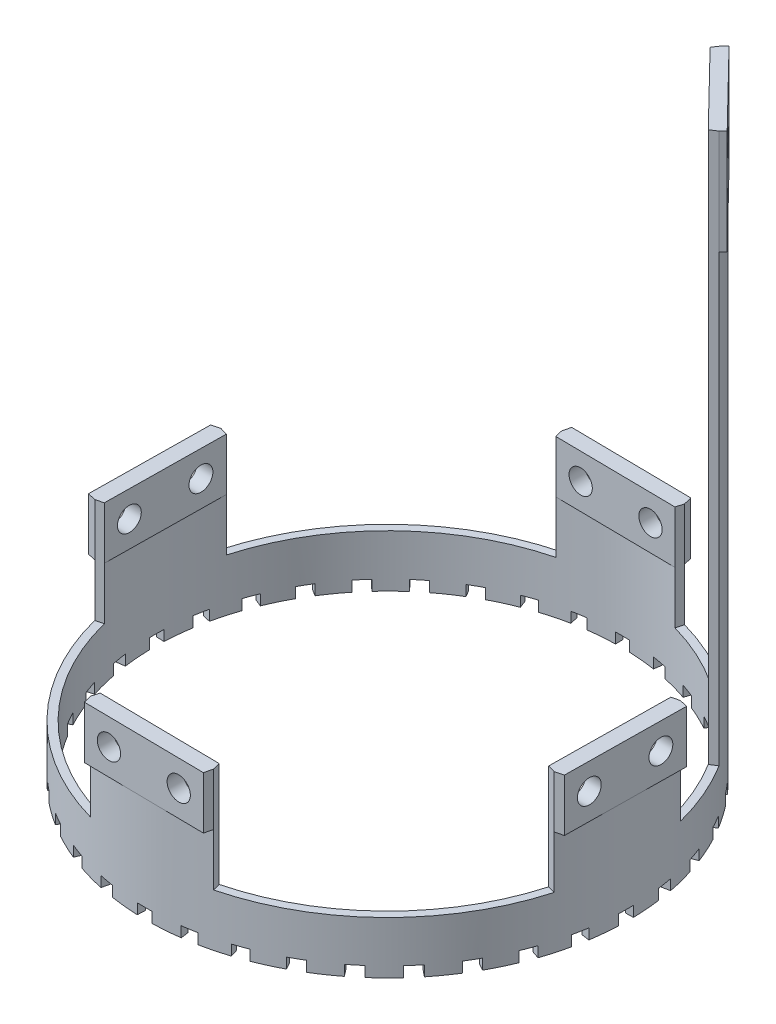
from build123d import *

# Parameters (mm, degrees)
SKETCH_1_R          = 46
SKETCH_1_R_2        = 44.5
EXTRUDE_1_DEPTH     = 10
EXTRUDE_2_DEPTH     = 20
EXTRUDE_4_DEPTH     = 10
SKETCH_5_R          = 2.25
CUT_EXTRUDE_1_DEPTH = 93.722097242
SKETCH_6_R          = 2.25
CUT_EXTRUDE_2_DEPTH = 93.722097242
CUT_EXTRUDE_3_DEPTH = 2
EXTRUDE_6_DEPTH     = 105
EXTRUDE_7_DEPTH     = 20
SKETCH_10_R         = 3
SKETCH_10_R_2       = 1.6
CUT_EXTRUDE_4_DEPTH = 20


with BuildPart() as part:
    # 草图1 → 凸台-拉伸1 (new body)
    with BuildSketch(Plane(origin=(0, 0, 0), x_dir=(1, 0, 0), z_dir=(0, 1, 0))):
        Circle(SKETCH_1_R)
        Circle(SKETCH_1_R_2, mode=Mode.SUBTRACT)
    extrude(amount=EXTRUDE_1_DEPTH)

    # 草图2 → 凸台-拉伸2 (add)
    with BuildSketch(Plane(origin=(0, 10, 0), x_dir=(1, 0, 0), z_dir=(0, 1, 0))):
        with BuildLine():
            Line((-10.973094766, 43.125876122), (-11.342974365, 44.579557339))
            ThreePointArc((-11.342974365, 44.579557339), (0.581566575, 45.996323552), (12.466474715, 44.278516328))
            Line((12.466474715, 44.278516328), (12.059959235, 42.834651665))
            ThreePointArc((12.059959235, 42.834651665), (0.562602448, 44.496443436), (-10.973094766, 43.125876122))
        make_face()
        with BuildLine():
            Line((43.125876122, 10.973094766), (44.579557339, 11.342974365))
            ThreePointArc((44.579557339, 11.342974365), (45.996323552, -0.581566575), (44.278516328, -12.466474715))
            Line((44.278516328, -12.466474715), (42.834651665, -12.059959235))
            ThreePointArc((42.834651665, -12.059959235), (44.496443436, -0.562602448), (43.125876122, 10.973094766))
        make_face()
        with BuildLine():
            Line((10.973094766, -43.125876122), (11.342974365, -44.579557339))
            ThreePointArc((11.342974365, -44.579557339), (-0.581566575, -45.996323552), (-12.466474715, -44.278516328))
            Line((-12.466474715, -44.278516328), (-12.059959235, -42.834651665))
            ThreePointArc((-12.059959235, -42.834651665), (-0.562602448, -44.496443436), (10.973094766, -43.125876122))
        make_face()
        with BuildLine():
            Line((-43.125876122, -10.973094766), (-44.579557339, -11.342974365))
            ThreePointArc((-44.579557339, -11.342974365), (-45.996323552, 0.581566575), (-44.278516328, 12.466474715))
            Line((-44.278516328, 12.466474715), (-42.834651665, 12.059959235))
            ThreePointArc((-42.834651665, 12.059959235), (-44.496443436, 0.562602448), (-43.125876122, -10.973094766))
        make_face()
    extrude(amount=EXTRUDE_2_DEPTH)

    # 草图3 → 凸台-拉伸4 (add)
    with BuildSketch(Plane(origin=(0, 30, 0), x_dir=(1, 0, 0), z_dir=(0, 1, 0))):
        Polygon((-10.973094765, 46.142417942), (-11.342974365, 44.579557339), (-10.973094766, 43.125876122), (12.059959235, 42.834651665), (12.466474715, 44.278516328), (12.059959236, 45.851193485), align=None)
        Polygon((44.278516328, -12.466474715), (42.834651666, -12.059959235), (43.125876122, 10.973094767), (44.57955734, 11.342974365), (46.142417943, 10.973094766), (45.851193486, -12.059959236), align=None)
        Polygon((-12.466474714, -44.278516328), (-12.059959234, -42.834651665), (10.973094767, -43.125876122), (11.342974366, -44.579557339), (10.973094766, -46.142417942), (-12.059959235, -45.851193486), align=None)
        Polygon((-44.278516327, 12.466474714), (-42.834651664, 12.059959234), (-43.125876121, -10.973094767), (-44.579557339, -11.342974366), (-46.142417942, -10.973094766), (-45.851193485, 12.059959235), align=None)
    extrude(amount=-EXTRUDE_4_DEPTH)

    # 草图5 → 切除-拉伸1 (cut, through all)
    with BuildSketch(Plane(origin=(-45.996323552, 0, -0.581566575), x_dir=(-0.012642752, 0, 0.999920077), z_dir=(-0.999920077, 0, -0.012642752))):
        with Locations((-6.711862611, 25)):
            Circle(SKETCH_5_R)
        with Locations((6.788137389, 25)):
            Circle(SKETCH_5_R)
    extrude(amount=-CUT_EXTRUDE_1_DEPTH, mode=Mode.SUBTRACT)

    # 草图6 → 切除-拉伸2 (cut, through all)
    with BuildSketch(Plane(origin=(-0.581566575, 0, 45.996323552), x_dir=(0.999920077, 0, 0.012642752), z_dir=(-0.012642752, 0, 0.999920077))):
        with Locations((-6.718224297, 25)):
            Circle(SKETCH_6_R)
        with Locations((6.781764795, 24.982838189)):
            Circle(SKETCH_6_R)
    extrude(amount=-CUT_EXTRUDE_2_DEPTH, mode=Mode.SUBTRACT)

    # 草图7 → 切除-拉伸3 (cut)
    with BuildSketch(Plane.XZ):
        with BuildLine():
            Line((-1.773747929, 44.464635592), (-1.833537185, 45.963443533))
            ThreePointArc((-1.833537185, 45.963443533), (-0.429026779, 45.997999261), (0.975883831, 45.989647213))
            Line((0.975883831, 45.989647213), (0.944061532, 44.489984804))
            ThreePointArc((0.944061532, 44.489984804), (-0.415036775, 44.498064503), (-1.773747929, 44.464635592))
        make_face()
        with BuildLine():
            Line((5.974402229, 44.097125961), (6.175786574, 45.583545937))
            ThreePointArc((6.175786574, 45.583545937), (7.56495985, 45.373686014), (8.947076393, 45.121500684))
            Line((8.947076393, 45.121500684), (8.655323902, 43.650147401))
            ThreePointArc((8.655323902, 43.650147401), (7.318276377, 43.894109296), (5.974402229, 44.097125961))
        make_face()
        with BuildLine():
            Line((13.541023198, 42.389747472), (13.997462182, 43.818615364))
            ThreePointArc((13.997462182, 43.818615364), (15.329089002, 43.370716277), (16.646416566, 42.88236019))
            Line((16.646416566, 42.88236019), (16.103598635, 41.484022358))
            ThreePointArc((16.103598635, 41.484022358), (14.829227404, 41.95645379), (13.541023198, 42.389747472))
        make_face()
        with BuildLine():
            Line((20.69620703, 39.394377957), (21.393831986, 40.722278337))
            ThreePointArc((21.393831986, 40.722278337), (22.627451541, 40.049949273), (23.839963795, 39.340260882))
            Line((23.839963795, 39.340260882), (23.062573672, 38.057426288))
            ThreePointArc((23.062573672, 38.057426288), (21.889599861, 38.743972666), (20.69620703, 39.394377957))
        make_face()
        with BuildLine():
            Line((27.222547083, 35.202030202), (28.14016103, 36.388615489))
            ThreePointArc((28.14016103, 36.388615489), (29.238290416, 35.512284826), (30.309145788, 34.602827653))
            Line((30.309145788, 34.602827653), (29.320804078, 33.474474577))
            ThreePointArc((29.320804078, 33.474474577), (28.284867902, 34.354275538), (27.222547083, 35.202030202))
        make_face()
        with BuildLine():
            Line((32.921743819, 29.940086572), (34.031465521, 30.949302973))
            ThreePointArc((34.031465521, 30.949302973), (34.960738631, 29.895597575), (35.857399724, 28.814005016))
            Line((35.857399724, 28.814005016), (34.688136689, 27.874417896))
            ThreePointArc((34.688136689, 27.874417896), (33.820714545, 28.920741133), (32.921743819, 29.940086572))
        make_face()
        with BuildLine():
            Line((37.620630028, 23.768428562), (38.888741152, 24.569611547))
            ThreePointArc((38.888741152, 24.569611547), (39.620922494, 23.37054772), (40.316144713, 22.149683417))
            Line((40.316144713, 22.149683417), (39.00148782, 21.427411132))
            ThreePointArc((39.00148782, 21.427411132), (38.328935891, 22.608464642), (37.620630028, 23.768428562))
        make_face()
        with BuildLine():
            Line((41.17643243, 16.874578878), (42.564402063, 17.443384907))
            ThreePointArc((42.564402063, 17.443384907), (43.077244676, 16.135395598), (43.549904046, 14.812354896))
            Line((43.549904046, 14.812354896), (42.129798479, 14.329343323))
            ThreePointArc((42.129798479, 14.329343323), (41.672551915, 15.609241394), (41.17643243, 16.874578878))
        make_face()
        with BuildLine():
            Line((43.48110977, 9.468003653), (44.946765155, 9.787149844))
            ThreePointArc((44.946765155, 9.787149844), (45.224686577, 8.409977646), (45.460421582, 7.024960467))
            Line((45.460421582, 7.024960467), (43.978016531, 6.795885669))
            ThreePointArc((43.978016531, 6.795885669), (43.749968537, 8.135739244), (43.48110977, 9.468003653))
        make_face()
        with BuildLine():
            Line((44.464635592, 1.773747929), (45.963443533, 1.833537185))
            ThreePointArc((45.963443533, 1.833537185), (45.997999261, 0.429026779), (45.989647213, -0.975883831))
            Line((45.989647213, -0.975883831), (44.489984804, -0.944061532))
            ThreePointArc((44.489984804, -0.944061532), (44.498064503, 0.415036775), (44.464635592, 1.773747929))
        make_face()
        with BuildLine():
            Line((44.097125961, -5.974402229), (45.583545937, -6.175786574))
            ThreePointArc((45.583545937, -6.175786574), (45.373686014, -7.56495985), (45.121500684, -8.947076393))
            Line((45.121500684, -8.947076393), (43.650147401, -8.655323902))
            ThreePointArc((43.650147401, -8.655323902), (43.894109296, -7.318276377), (44.097125961, -5.974402229))
        make_face()
        with BuildLine():
            Line((42.389747472, -13.541023198), (43.818615364, -13.997462182))
            ThreePointArc((43.818615364, -13.997462182), (43.370716277, -15.329089002), (42.88236019, -16.646416566))
            Line((42.88236019, -16.646416566), (41.484022358, -16.103598635))
            ThreePointArc((41.484022358, -16.103598635), (41.95645379, -14.829227404), (42.389747472, -13.541023198))
        make_face()
        with BuildLine():
            Line((39.394377957, -20.69620703), (40.722278337, -21.393831986))
            ThreePointArc((40.722278337, -21.393831986), (40.049949273, -22.627451541), (39.340260882, -23.839963795))
            Line((39.340260882, -23.839963795), (38.057426288, -23.062573672))
            ThreePointArc((38.057426288, -23.062573672), (38.743972666, -21.889599861), (39.394377957, -20.69620703))
        make_face()
        with BuildLine():
            Line((35.202030202, -27.222547083), (36.388615489, -28.14016103))
            ThreePointArc((36.388615489, -28.14016103), (35.512284826, -29.238290416), (34.602827653, -30.309145788))
            Line((34.602827653, -30.309145788), (33.474474577, -29.320804078))
            ThreePointArc((33.474474577, -29.320804078), (34.354275538, -28.284867902), (35.202030202, -27.222547083))
        make_face()
        with BuildLine():
            Line((29.940086572, -32.921743819), (30.949302973, -34.031465521))
            ThreePointArc((30.949302973, -34.031465521), (29.895597575, -34.960738631), (28.814005016, -35.857399724))
            Line((28.814005016, -35.857399724), (27.874417896, -34.688136689))
            ThreePointArc((27.874417896, -34.688136689), (28.920741133, -33.820714545), (29.940086572, -32.921743819))
        make_face()
        with BuildLine():
            Line((23.768428562, -37.620630028), (24.569611547, -38.888741152))
            ThreePointArc((24.569611547, -38.888741152), (23.37054772, -39.620922494), (22.149683417, -40.316144713))
            Line((22.149683417, -40.316144713), (21.427411132, -39.00148782))
            ThreePointArc((21.427411132, -39.00148782), (22.608464642, -38.328935891), (23.768428562, -37.620630028))
        make_face()
        with BuildLine():
            Line((16.874578878, -41.17643243), (17.443384907, -42.564402063))
            ThreePointArc((17.443384907, -42.564402063), (16.135395598, -43.077244676), (14.812354896, -43.549904046))
            Line((14.812354896, -43.549904046), (14.329343323, -42.129798479))
            ThreePointArc((14.329343323, -42.129798479), (15.609241394, -41.672551915), (16.874578878, -41.17643243))
        make_face()
        with BuildLine():
            Line((9.468003653, -43.48110977), (9.787149844, -44.946765155))
            ThreePointArc((9.787149844, -44.946765155), (8.409977646, -45.224686577), (7.024960467, -45.460421582))
            Line((7.024960467, -45.460421582), (6.795885669, -43.978016531))
            ThreePointArc((6.795885669, -43.978016531), (8.135739244, -43.749968537), (9.468003653, -43.48110977))
        make_face()
        with BuildLine():
            Line((1.773747929, -44.464635592), (1.833537185, -45.963443533))
            ThreePointArc((1.833537185, -45.963443533), (0.429026779, -45.997999261), (-0.975883831, -45.989647213))
            Line((-0.975883831, -45.989647213), (-0.944061532, -44.489984804))
            ThreePointArc((-0.944061532, -44.489984804), (0.415036775, -44.498064503), (1.773747929, -44.464635592))
        make_face()
        with BuildLine():
            Line((-5.974402229, -44.097125961), (-6.175786574, -45.583545937))
            ThreePointArc((-6.175786574, -45.583545937), (-7.56495985, -45.373686014), (-8.947076393, -45.121500684))
            Line((-8.947076393, -45.121500684), (-8.655323902, -43.650147401))
            ThreePointArc((-8.655323902, -43.650147401), (-7.318276377, -43.894109296), (-5.974402229, -44.097125961))
        make_face()
        with BuildLine():
            Line((-13.541023198, -42.389747472), (-13.997462182, -43.818615364))
            ThreePointArc((-13.997462182, -43.818615364), (-15.329089002, -43.370716277), (-16.646416566, -42.88236019))
            Line((-16.646416566, -42.88236019), (-16.103598635, -41.484022358))
            ThreePointArc((-16.103598635, -41.484022358), (-14.829227404, -41.95645379), (-13.541023198, -42.389747472))
        make_face()
        with BuildLine():
            Line((-20.69620703, -39.394377957), (-21.393831986, -40.722278337))
            ThreePointArc((-21.393831986, -40.722278337), (-22.627451541, -40.049949273), (-23.839963795, -39.340260882))
            Line((-23.839963795, -39.340260882), (-23.062573672, -38.057426288))
            ThreePointArc((-23.062573672, -38.057426288), (-21.889599861, -38.743972666), (-20.69620703, -39.394377957))
        make_face()
        with BuildLine():
            Line((-27.222547083, -35.202030202), (-28.14016103, -36.388615489))
            ThreePointArc((-28.14016103, -36.388615489), (-29.238290416, -35.512284826), (-30.309145788, -34.602827653))
            Line((-30.309145788, -34.602827653), (-29.320804078, -33.474474577))
            ThreePointArc((-29.320804078, -33.474474577), (-28.284867902, -34.354275538), (-27.222547083, -35.202030202))
        make_face()
        with BuildLine():
            Line((-32.921743819, -29.940086572), (-34.031465521, -30.949302973))
            ThreePointArc((-34.031465521, -30.949302973), (-34.960738631, -29.895597575), (-35.857399724, -28.814005016))
            Line((-35.857399724, -28.814005016), (-34.688136689, -27.874417896))
            ThreePointArc((-34.688136689, -27.874417896), (-33.820714545, -28.920741133), (-32.921743819, -29.940086572))
        make_face()
        with BuildLine():
            Line((-37.620630028, -23.768428562), (-38.888741152, -24.569611547))
            ThreePointArc((-38.888741152, -24.569611547), (-39.620922494, -23.37054772), (-40.316144713, -22.149683417))
            Line((-40.316144713, -22.149683417), (-39.00148782, -21.427411132))
            ThreePointArc((-39.00148782, -21.427411132), (-38.328935891, -22.608464642), (-37.620630028, -23.768428562))
        make_face()
        with BuildLine():
            Line((-41.17643243, -16.874578878), (-42.564402063, -17.443384907))
            ThreePointArc((-42.564402063, -17.443384907), (-43.077244676, -16.135395598), (-43.549904046, -14.812354896))
            Line((-43.549904046, -14.812354896), (-42.129798479, -14.329343323))
            ThreePointArc((-42.129798479, -14.329343323), (-41.672551915, -15.609241394), (-41.17643243, -16.874578878))
        make_face()
        with BuildLine():
            Line((-43.48110977, -9.468003653), (-44.946765155, -9.787149844))
            ThreePointArc((-44.946765155, -9.787149844), (-45.224686577, -8.409977646), (-45.460421582, -7.024960467))
            Line((-45.460421582, -7.024960467), (-43.978016531, -6.795885669))
            ThreePointArc((-43.978016531, -6.795885669), (-43.749968537, -8.135739244), (-43.48110977, -9.468003653))
        make_face()
        with BuildLine():
            Line((-44.464635592, -1.773747929), (-45.963443533, -1.833537185))
            ThreePointArc((-45.963443533, -1.833537185), (-45.997999261, -0.429026779), (-45.989647213, 0.975883831))
            Line((-45.989647213, 0.975883831), (-44.489984804, 0.944061532))
            ThreePointArc((-44.489984804, 0.944061532), (-44.498064503, -0.415036775), (-44.464635592, -1.773747929))
        make_face()
        with BuildLine():
            Line((-44.097125961, 5.974402229), (-45.583545937, 6.175786574))
            ThreePointArc((-45.583545937, 6.175786574), (-45.373686014, 7.56495985), (-45.121500684, 8.947076393))
            Line((-45.121500684, 8.947076393), (-43.650147401, 8.655323902))
            ThreePointArc((-43.650147401, 8.655323902), (-43.894109296, 7.318276377), (-44.097125961, 5.974402229))
        make_face()
        with BuildLine():
            Line((-42.389747472, 13.541023198), (-43.818615364, 13.997462182))
            ThreePointArc((-43.818615364, 13.997462182), (-43.370716277, 15.329089002), (-42.88236019, 16.646416566))
            Line((-42.88236019, 16.646416566), (-41.484022358, 16.103598635))
            ThreePointArc((-41.484022358, 16.103598635), (-41.95645379, 14.829227404), (-42.389747472, 13.541023198))
        make_face()
        with BuildLine():
            Line((-39.394377957, 20.69620703), (-40.722278337, 21.393831986))
            ThreePointArc((-40.722278337, 21.393831986), (-40.049949273, 22.627451541), (-39.340260882, 23.839963795))
            Line((-39.340260882, 23.839963795), (-38.057426288, 23.062573672))
            ThreePointArc((-38.057426288, 23.062573672), (-38.743972666, 21.889599861), (-39.394377957, 20.69620703))
        make_face()
        with BuildLine():
            Line((-35.202030202, 27.222547083), (-36.388615489, 28.14016103))
            ThreePointArc((-36.388615489, 28.14016103), (-35.512284826, 29.238290416), (-34.602827653, 30.309145788))
            Line((-34.602827653, 30.309145788), (-33.474474577, 29.320804078))
            ThreePointArc((-33.474474577, 29.320804078), (-34.354275538, 28.284867902), (-35.202030202, 27.222547083))
        make_face()
        with BuildLine():
            Line((-29.940086572, 32.921743819), (-30.949302973, 34.031465521))
            ThreePointArc((-30.949302973, 34.031465521), (-29.895597575, 34.960738631), (-28.814005016, 35.857399724))
            Line((-28.814005016, 35.857399724), (-27.874417896, 34.688136689))
            ThreePointArc((-27.874417896, 34.688136689), (-28.920741133, 33.820714545), (-29.940086572, 32.921743819))
        make_face()
        with BuildLine():
            Line((-23.768428562, 37.620630028), (-24.569611547, 38.888741152))
            ThreePointArc((-24.569611547, 38.888741152), (-23.37054772, 39.620922494), (-22.149683417, 40.316144713))
            Line((-22.149683417, 40.316144713), (-21.427411132, 39.00148782))
            ThreePointArc((-21.427411132, 39.00148782), (-22.608464642, 38.328935891), (-23.768428562, 37.620630028))
        make_face()
        with BuildLine():
            Line((-16.874578878, 41.17643243), (-17.443384907, 42.564402063))
            ThreePointArc((-17.443384907, 42.564402063), (-16.135395598, 43.077244676), (-14.812354896, 43.549904046))
            Line((-14.812354896, 43.549904046), (-14.329343323, 42.129798479))
            ThreePointArc((-14.329343323, 42.129798479), (-15.609241394, 41.672551915), (-16.874578878, 41.17643243))
        make_face()
        with BuildLine():
            Line((-9.468003653, 43.48110977), (-9.787149844, 44.946765155))
            ThreePointArc((-9.787149844, 44.946765155), (-8.409977646, 45.224686577), (-7.024960467, 45.460421582))
            Line((-7.024960467, 45.460421582), (-6.795885669, 43.978016531))
            ThreePointArc((-6.795885669, 43.978016531), (-8.135739244, 43.749968537), (-9.468003653, 43.48110977))
        make_face()
    extrude(amount=-CUT_EXTRUDE_3_DEPTH, mode=Mode.SUBTRACT)

    # 草图8 → 凸台-拉伸6 (add)
    with BuildSketch(Plane(origin=(0, 10, 0), x_dir=(1, 0, 0), z_dir=(0, 1, 0))):
        with BuildLine():
            Line((25.204294905, 38.48043033), (24.382415723, 37.225633688))
            ThreePointArc((24.382415723, 37.225633688), (31.861556899, 31.065916886), (37.830205838, 23.433427539))
            Line((37.830205838, 23.433427539), (39.105381316, 24.223318355))
            ThreePointArc((39.105381316, 24.223318355), (32.935541963, 32.113082624), (25.204294905, 38.48043033))
        make_face()
    extrude(amount=EXTRUDE_6_DEPTH)

    # 草图9 → 凸台-拉伸7 (add)
    with BuildSketch(Plane(origin=(0, 115, 0), x_dir=(1, 0, 0), z_dir=(0, 1, 0))):
        Polygon((24.382415723, 37.225633688), (37.830205838, 23.433427539), (39.105381316, 24.223318355), (39.886085168, 24.984526637), (25.984998757, 39.241638611), (25.204294905, 38.48043033), align=None)
    extrude(amount=-EXTRUDE_7_DEPTH)

    # 草图10 → 切除-拉伸4 (cut)
    with BuildSketch(Plane(origin=(32.935541963, 0, -32.113082624), x_dir=(-0.698110492, 0, -0.715990043), z_dir=(0.715990043, 0, -0.698110492))):
        with Locations((0, 105)):
            Circle(SKETCH_10_R)
        with Locations((-4.949747468, 109.949747468)):
            Circle(SKETCH_10_R_2)
        with Locations((-4.949747468, 100.050252532)):
            Circle(SKETCH_10_R_2)
        with Locations((4.949747468, 100.050252532)):
            Circle(SKETCH_10_R_2)
        with Locations((4.949747468, 109.949747468)):
            Circle(SKETCH_10_R_2)
    extrude(amount=-CUT_EXTRUDE_4_DEPTH, mode=Mode.SUBTRACT)


solid = part.part
